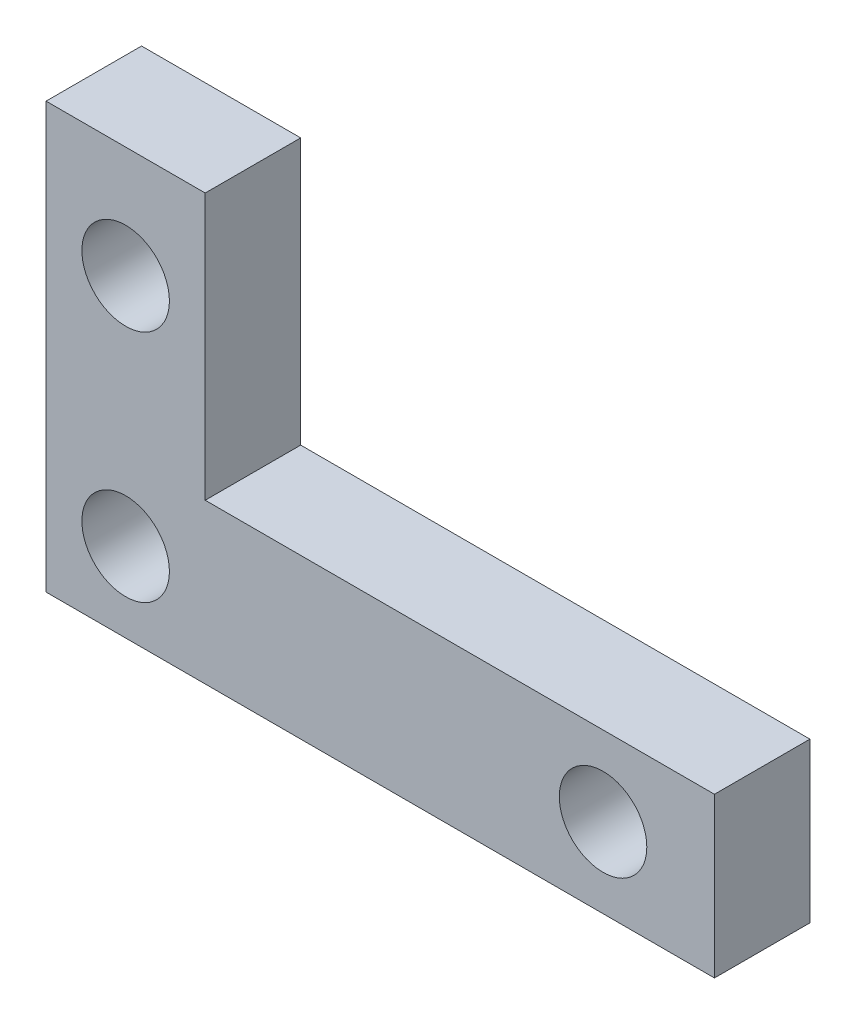
from build123d import *

# Parameters (mm, degrees)
SKETCH1_R           = 1.375
BOSS_EXTRUDE1_DEPTH = 3


with BuildPart() as part:
    # Sketch1 → Boss-Extrude1 (new body)
    with BuildSketch(Plane.XY):
        Polygon((0, 0), (21, 0), (21, 5), (5, 5), (5, 13.36), (0, 13.36), align=None)
        with Locations((17.5, 2.5)):
            Circle(SKETCH1_R, mode=Mode.SUBTRACT)
        with Locations((2.5, 2.5)):
            Circle(SKETCH1_R, mode=Mode.SUBTRACT)
        with Locations((2.5, 9.86)):
            Circle(SKETCH1_R, mode=Mode.SUBTRACT)
    extrude(amount=BOSS_EXTRUDE1_DEPTH)


solid = part.part
